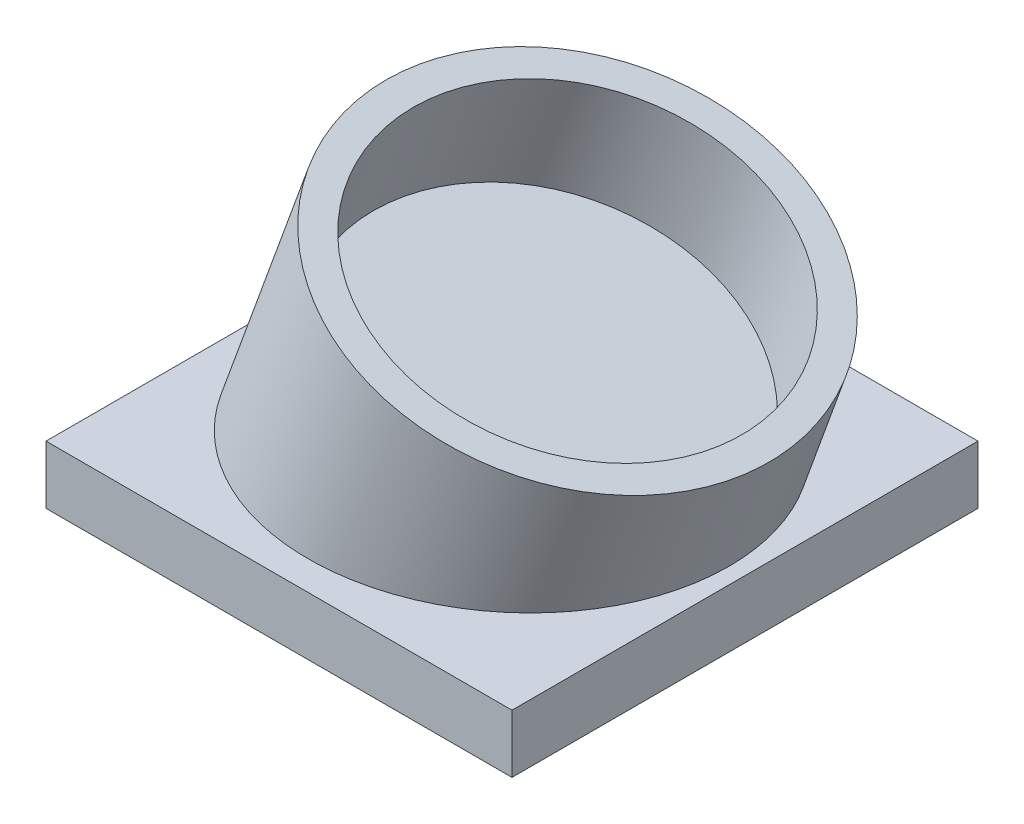
from build123d import *

# Parameters (mm, degrees)
SKETCH1_W           = 101.6
SKETCH1_H           = 101.6
BOSS_EXTRUDE1_DEPTH = 12.7
SKETCH4_R           = 44.45
SKETCH4_R_2         = 38.1
BOSS_EXTRUDE5_DEPTH = 1
BOSS_EXTRUDE6_REACH = 141.847
SKETCH7_R           = 44.45
SKETCH8_R           = 44.45
SKETCH8_R_2         = 38.1
BOSS_EXTRUDE7_DEPTH = 24.4


with BuildPart() as part:
    # Sketch1 → Boss-Extrude1 (new body)
    with BuildSketch(Plane(origin=(0, 0, 0), x_dir=(1, 0, 0), z_dir=(0, 1, 0))):
        with Locations((50.8, 50.8)):
            Rectangle(SKETCH1_W, SKETCH1_H)
    extrude(amount=BOSS_EXTRUDE1_DEPTH)

    # Boss-Extrude6: up to this face of the body (flat: up to its plane)
    boss_extrude6_end = Plane(part.part.faces().sort_by_distance((50.8, 12.7, -50.8))[0])
    # Sketch7 → Boss-Extrude6 (add, up to the picked face)
    with BuildSketch(Plane(origin=(15.624623468, 42.928300165, 0), x_dir=(0.9396926207859082, -0.34202014332566943, 0), z_dir=(-0.34202014332566943, -0.9396926207859082, 0)), mode=Mode.PRIVATE) as boss_extrude6_sk1:
        with Locations(Location((43.392729316, -50.8, 0), (0, 0, 180))):
            Circle(SKETCH7_R)
    boss_extrude6_tool1 = split(extrude(boss_extrude6_sk1.sketch, amount=BOSS_EXTRUDE6_REACH, mode=Mode.PRIVATE), bisect_by=boss_extrude6_end, keep=Keep.BOTH, mode=Mode.PRIVATE)


with BuildPart() as body_2:
    # Sketch4 → Boss-Extrude5 (new body)
    with BuildSketch(Plane(origin=(15.966643611, 43.867992786, 0), x_dir=(0, 0, -1), z_dir=(0.34202014332566943, 0.9396926207859081, 0))):
        with Locations(Location((50.8, -43.392729316, 0), (0, 0, 90))):
            Circle(SKETCH4_R)
        with Locations(Location((50.8, -43.392729316, 0), (0, 0, 90))):
            Circle(SKETCH4_R_2, mode=Mode.SUBTRACT)
    extrude(amount=-BOSS_EXTRUDE5_DEPTH)


with BuildPart() as part_1:
    add(part.part)

    add(body_2.part)  # Boss-Extrude6 merges body 2
    add(boss_extrude6_tool1.solids().sort_by(Axis((56.400451, 28.087113, -50.8), (-0.34202014332566943, -0.9396926207859082, 0)))[0])

    # Sketch8 → Boss-Extrude7 (add)
    with BuildSketch(Plane(origin=(15.966643611, 43.867992786, 0), x_dir=(0.9396926207859082, -0.34202014332566943, 0), z_dir=(0.34202014332566943, 0.9396926207859082, 0))):
        with Locations(Location((43.392729316, 50.8, 0), (0, 0, 180))):
            Circle(SKETCH8_R)
        with Locations(Location((43.392729316, 50.8, 0), (0, 0, 180))):
            Circle(SKETCH8_R_2, mode=Mode.SUBTRACT)
    extrude(amount=BOSS_EXTRUDE7_DEPTH)


solid = part_1.part
